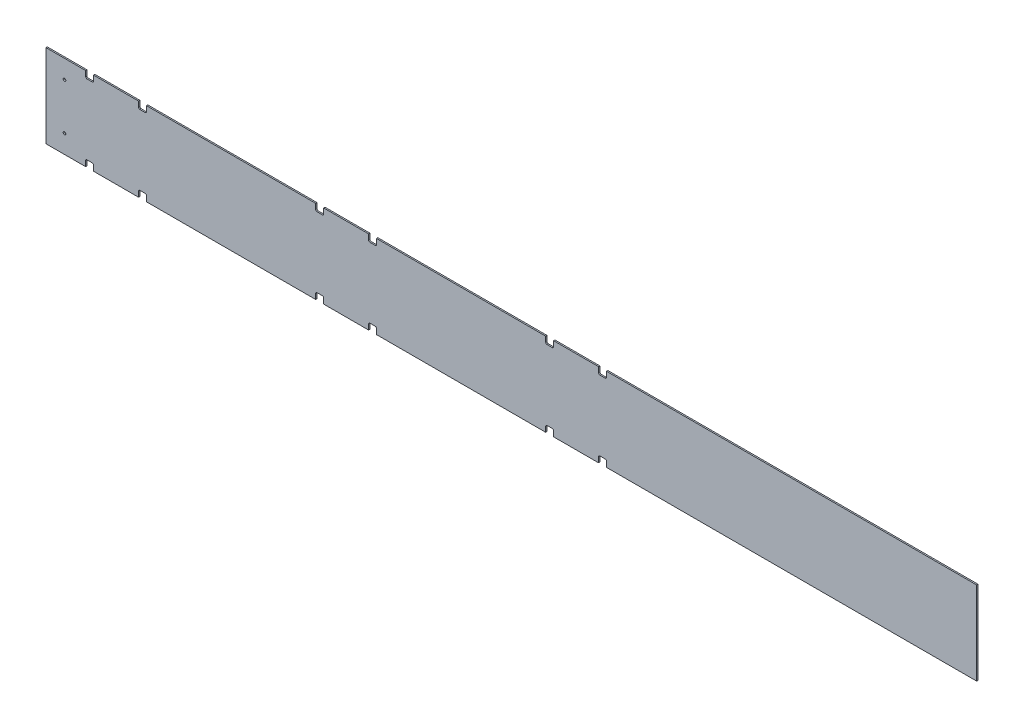
from build123d import *

# Parameters (mm, degrees)
SKETCH1_W                   = 2235.2
SKETCH1_H                   = 200.025
BOSS_EXTRUDE1_DEPTH         = 3.175
SKETCH2_W                   = 19.05
SKETCH2_H                   = 15.875
CUT_EXTRUDE1_DEPTH          = 4.175
F_1_4_0_25_DIAMETER_HOLE1_D = 6.35
FILLET1_R                   = 3.175
FILLET1_OF_MIRROR1_R        = 3.175


with BuildPart() as part:
    # Sketch1 → Boss-Extrude1 (new body)
    with BuildSketch(Plane.XY):
        Rectangle(SKETCH1_W, SKETCH1_H)
    extrude(amount=BOSS_EXTRUDE1_DEPTH)

    # Sketch2 → Cut-Extrude1 (cut, through all)
    with BuildSketch(Plane(origin=(0, 0, 0), x_dir=(-1, 0, 0), z_dir=(0, 0, -1))):
        with Locations((-219.075, -92.075)):
            Rectangle(SKETCH2_W, SKETCH2_H)
        with Locations((-92.075, -92.075)):
            Rectangle(SKETCH2_W, SKETCH2_H)
        with Locations((333.375, -92.075)):
            Rectangle(SKETCH2_W, SKETCH2_H)
        with Locations((460.375, -92.075)):
            Rectangle(SKETCH2_W, SKETCH2_H)
        with Locations((885.825, -92.075)):
            Rectangle(SKETCH2_W, SKETCH2_H)
        with Locations((1012.825, -92.075)):
            Rectangle(SKETCH2_W, SKETCH2_H)
    cut_extrude1 = extrude(amount=-CUT_EXTRUDE1_DEPTH, mode=Mode.SUBTRACT)

    # 1/4 (0.25) Diameter Hole1 (through all)
    with Locations(Plane(origin=(0, 0, 0), x_dir=(-1, 0, 0), z_dir=(0, 0, -1))):
        with Locations((1073.15, -55.5625), (1073.15, 55.5625)):
            Hole(F_1_4_0_25_DIAMETER_HOLE1_D / 2)

    # Fillet1
    fillet1_edges = [part.edges().sort_by_distance(p)[0] for p in [
        (228.6, -84.1375, 1.5875),
        (209.55, -84.1375, 1.5875),
        (101.6, -84.1375, 1.5875),
        (82.55, -84.1375, 1.5875),
        (-323.85, -84.1375, 1.5875),
        (-342.9, -84.1375, 1.5875),
        (-450.85, -84.1375, 1.5875),
        (-469.9, -84.1375, 1.5875),
        (-876.3, -84.1375, 1.5875),
        (-895.35, -84.1375, 1.5875),
        (-1003.3, -84.1375, 1.5875),
        (-1022.35, -84.1375, 1.5875),
    ]]
    fillet(fillet1_edges, radius=FILLET1_R)

    # Mirror1: Cut-Extrude1 across plane
    add(cut_extrude1.mirror(Plane.ZX), mode=Mode.SUBTRACT)

    # Fillet1 of Mirror1
    fillet1_of_mirror1_edges = [part.edges().sort_by_distance(p)[0] for p in [
        (228.6, 84.1375, 1.5875),
        (209.55, 84.1375, 1.5875),
        (101.6, 84.1375, 1.5875),
        (82.55, 84.1375, 1.5875),
        (-323.85, 84.1375, 1.5875),
        (-342.9, 84.1375, 1.5875),
        (-450.85, 84.1375, 1.5875),
        (-469.9, 84.1375, 1.5875),
        (-876.3, 84.1375, 1.5875),
        (-895.35, 84.1375, 1.5875),
        (-1003.3, 84.1375, 1.5875),
        (-1022.35, 84.1375, 1.5875),
    ]]
    fillet(fillet1_of_mirror1_edges, radius=FILLET1_OF_MIRROR1_R)


solid = part.part
